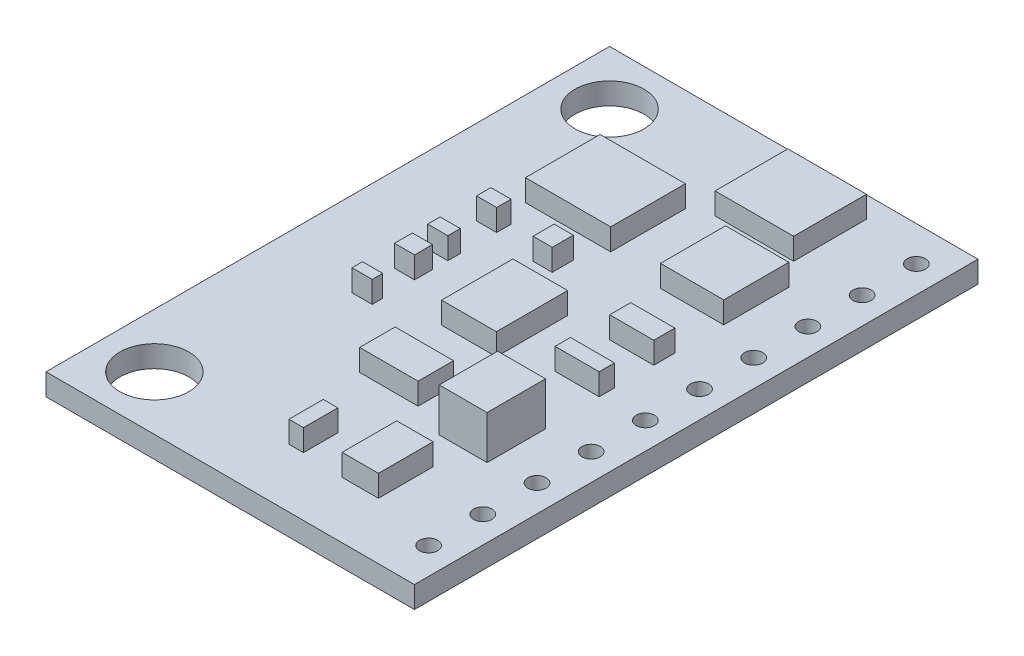
from build123d import *

# Parameters (mm, degrees)
SKETCH2_W           = 17
SKETCH2_H           = 26
BOSS_EXTRUDE1_DEPTH = 1
SKETCH3_R           = 0.825554505
SKETCH3_R_2         = 0.799067601
SKETCH3_R_3         = 0.4
SKETCH3_R_4         = 0.016836885
SKETCH3_W           = 3.624022482
SKETCH3_H           = 3.358967559
SKETCH3_W_2         = 2.916998144
SKETCH3_H_2         = 3.005392027
SKETCH3_W_3         = 3.9335278
SKETCH3_H_3         = 3.447361443
SKETCH3_W_4         = 0.928135773
SKETCH3_H_4         = 0.662954124
SKETCH3_W_5         = 0.883938831
SKETCH3_H_5         = 0.972332715
SKETCH3_W_6         = 2.524073743
SKETCH3_H_6         = 3.291762325
SKETCH3_H_7         = 0.574560241
SKETCH3_H_8         = 0.82518615
SKETCH3_H_9         = 0.486166357
SKETCH3_W_7         = 2.696013436
SKETCH3_H_10        = 1.635286838
SKETCH3_W_8         = 2.033059313
SKETCH3_H_11        = 0.972332714
SKETCH3_H_12        = 0.707151065
SKETCH3_W_9         = 1.676172691
SKETCH3_H_13        = 2.519225669
SKETCH3_W_10        = 0.670281766
SKETCH3_H_14        = 1.583920148
BOSS_EXTRUDE2_DEPTH = 1
SKETCH4_R           = 1.59
SKETCH4_R_2         = 0.42
CUT_EXTRUDE1_DEPTH  = 3
SKETCH5_W           = 2.209847079
SKETCH5_H           = 2.696013435
BOSS_EXTRUDE3_DEPTH = 2


with BuildPart() as part:
    # Sketch2 → Boss-Extrude1 (new body)
    with BuildSketch(Plane(origin=(0, 0, 0), x_dir=(1, 0, 0), z_dir=(0, 1, 0))):
        Rectangle(SKETCH2_W, SKETCH2_H)
    extrude(amount=BOSS_EXTRUDE1_DEPTH)

    # Sketch3 → Boss-Extrude2 (add)
    with BuildSketch(Plane(origin=(0, 1, 0), x_dir=(1, 0, 0), z_dir=(0, 1, 0))):
        with Locations((-6, -10.5)):
            Circle(SKETCH3_R)
        with Locations((-6, 10.5)):
            Circle(SKETCH3_R_2)
        with Locations((7.26674642, 11.385525432)):
            Circle(SKETCH3_R_3)
        with Locations((7.26674642, 11.385525432)):
            Circle(SKETCH3_R_4, mode=Mode.SUBTRACT)
        with Locations((2.519162306, 10.342084328)):
            Rectangle(SKETCH3_W, SKETCH3_H)
        with Locations((3.800810248, 6.010784054)):
            Rectangle(SKETCH3_W_2, SKETCH3_H_2)
        with Locations((-2.232072277, 6.541147353)):
            Rectangle(SKETCH3_W_3, SKETCH3_H_3)
        with Locations((-4.132540764, 3.292672147)):
            Rectangle(SKETCH3_W_4, SKETCH3_H_4)
        with Locations((-1.237641092, 3.137982852)):
            Rectangle(SKETCH3_W_5, SKETCH3_H_5)
        with Locations((0.024395781, -0.364169856)):
            Rectangle(SKETCH3_W_6, SKETCH3_H_6)
        with Locations((-4.132540764, 0.994431186)):
            Rectangle(SKETCH3_W_4, SKETCH3_H_7)
        with Locations((-4.132540764, -0.412593075)):
            Rectangle(SKETCH3_W_4, SKETCH3_H_8)
        with Locations((-4.132540764, -2.54132414)):
            Rectangle(SKETCH3_W_4, SKETCH3_H_9)
        with Locations((0.110365627, -4.972155927)):
            Rectangle(SKETCH3_W_7, SKETCH3_H_10)
        with Locations((4.242779664, 1.767877663)):
            Rectangle(SKETCH3_W_8, SKETCH3_H_11)
        with Locations((4.242779664, -0.883938832)):
            Rectangle(SKETCH3_W_8, SKETCH3_H_12)
        with Locations((3.386837508, -9.126668435)):
            Rectangle(SKETCH3_W_9, SKETCH3_H_13)
        with Locations((0.335140883, -9.498757564)):
            Rectangle(SKETCH3_W_10, SKETCH3_H_14)
    extrude(amount=BOSS_EXTRUDE2_DEPTH)

    # Sketch4 → Cut-Extrude1 (cut, through all)
    with BuildSketch(Plane(origin=(0, 2, 0), x_dir=(1, 0, 0), z_dir=(0, 1, 0))):
        with Locations((-6, 10.5)):
            Circle(SKETCH4_R)
        with Locations((-6, -10.5)):
            Circle(SKETCH4_R)
        with Locations((7.26674642, 11.385525432)):
            Circle(SKETCH4_R_2)
        with Locations((7.26674642, 8.885525432)):
            Circle(SKETCH4_R_2)
        with Locations((7.26674642, 6.385525432)):
            Circle(SKETCH4_R_2)
        with Locations((7.26674642, 3.885525432)):
            Circle(SKETCH4_R_2)
        with Locations((7.26674642, 1.385525432)):
            Circle(SKETCH4_R_2)
        with Locations((7.26674642, -1.114474568)):
            Circle(SKETCH4_R_2)
        with Locations((7.26674642, -3.614474568)):
            Circle(SKETCH4_R_2)
        with Locations((7.26674642, -6.114474568)):
            Circle(SKETCH4_R_2)
        with Locations((7.26674642, -8.614474568)):
            Circle(SKETCH4_R_2)
        with Locations((7.26674642, -11.114474568)):
            Circle(SKETCH4_R_2)
    extrude(amount=-CUT_EXTRUDE1_DEPTH, mode=Mode.SUBTRACT)

    # Sketch5 → Boss-Extrude3 (add)
    with BuildSketch(Plane(origin=(0, 1, 0), x_dir=(1, 0, 0), z_dir=(0, 1, 0))):
        with Locations((4.19870945, -5.104746752)):
            Rectangle(SKETCH5_W, SKETCH5_H)
    extrude(amount=BOSS_EXTRUDE3_DEPTH)


solid = part.part
